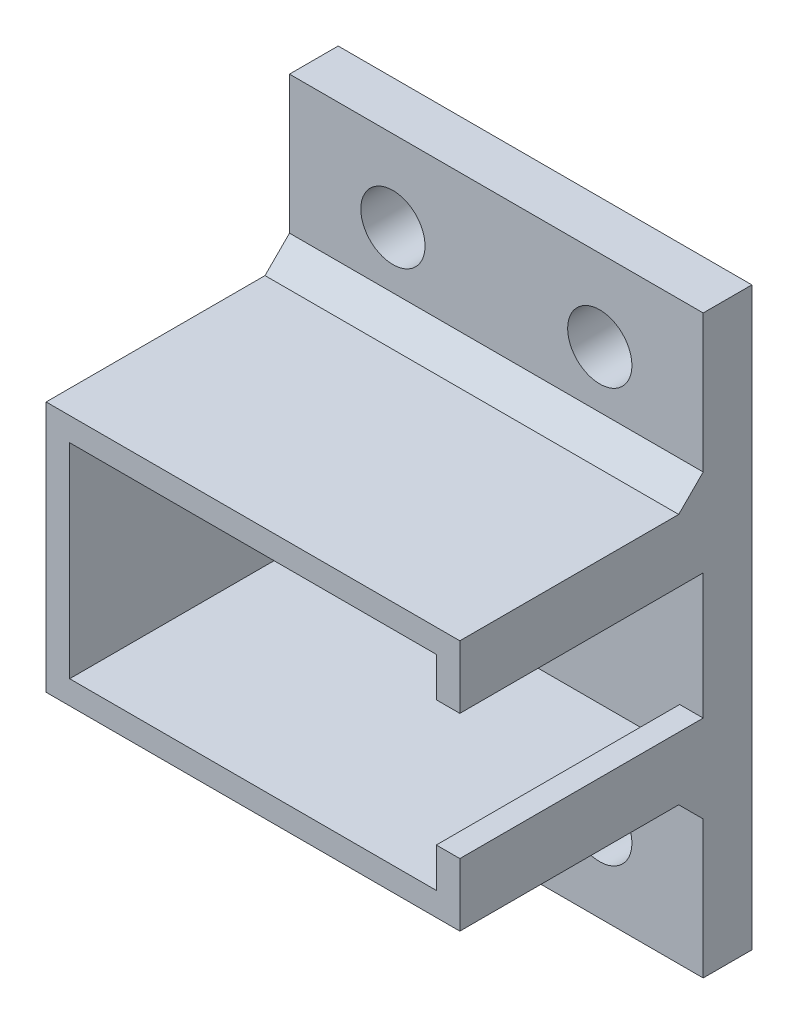
from build123d import *

# Parameters (mm, degrees)
SKETCH3_W                = 25.5
SKETCH3_H                = 15.5
BOSS_EXTRUDE2_DEPTH      = 18
SKETCH4_W                = 22.6
SKETCH4_H                = 12.6
CUT_EXTRUDE1_DEPTH       = 15
SKETCH7_W                = 25.5
SKETCH7_H                = 3
BOSS_EXTRUDE4_DEPTH      = 10
BOSS_EXTRUDE4_DEPTH_BACK = 25.5
SKETCH8_R                = 1.98
CUT_EXTRUDE2_DEPTH       = 16
CUT_EXTRUDE2_DEPTH_BACK  = 31
BOSS_EXTRUDE5_DEPTH      = 25.5
SKETCH10_W               = 15
SKETCH10_H               = 7.75
CUT_EXTRUDE3_DEPTH       = 5
CUT_EXTRUDE3_DEPTH_BACK  = 9


with BuildPart() as part:
    # Sketch3 → Boss-Extrude2 (new body)
    with BuildSketch(Plane.XY):
        with Locations((12.75, 7.75)):
            Rectangle(SKETCH3_W, SKETCH3_H)
    extrude(amount=BOSS_EXTRUDE2_DEPTH)

    # Sketch4 → Cut-Extrude1 (cut)
    with BuildSketch(Plane.XY.offset(18)):
        with Locations((12.750003743, 7.749991635)):
            Rectangle(SKETCH4_W, SKETCH4_H)
    extrude(amount=-CUT_EXTRUDE1_DEPTH, mode=Mode.SUBTRACT)

    # Sketch7 → Boss-Extrude4 (add, two sides)
    with BuildSketch(Plane.XZ) as boss_extrude4_sk:
        with Locations((12.75, 1.5)):
            Rectangle(SKETCH7_W, SKETCH7_H)
    extrude(amount=BOSS_EXTRUDE4_DEPTH)
    extrude(boss_extrude4_sk.sketch, amount=-BOSS_EXTRUDE4_DEPTH_BACK)

    # Sketch8 → Cut-Extrude2 (cut, two sides)
    with BuildSketch(Plane.XY.offset(3)) as cut_extrude2_sk:
        with Locations((19.125, 20.5)):
            Circle(SKETCH8_R)
        with Locations((6.375, -5)):
            Circle(SKETCH8_R)
        with Locations((6.375, 20.5)):
            Circle(SKETCH8_R)
        with Locations((19.125, -5)):
            Circle(SKETCH8_R)
    extrude(amount=CUT_EXTRUDE2_DEPTH, mode=Mode.SUBTRACT)
    extrude(cut_extrude2_sk.sketch, amount=-CUT_EXTRUDE2_DEPTH_BACK, mode=Mode.SUBTRACT)

    # Sketch9 → Boss-Extrude5 (add)
    with BuildSketch(Plane.ZY):
        Polygon((3, 17.01), (3, 15.5), (4.51, 15.5), align=None)
        Polygon((4.51, 0), (3, 0), (3, -1.51), align=None)
    extrude(amount=-BOSS_EXTRUDE5_DEPTH)

    # Sketch10 → Cut-Extrude3 (cut, two sides)
    with BuildSketch(Plane(origin=(25.5, 0, 0), x_dir=(0, 0, -1), z_dir=(1, 0, 0))) as cut_extrude3_sk:
        with Locations((-10.5, 7.75)):
            Rectangle(SKETCH10_W, SKETCH10_H)
    extrude(amount=CUT_EXTRUDE3_DEPTH, mode=Mode.SUBTRACT)
    extrude(cut_extrude3_sk.sketch, amount=-CUT_EXTRUDE3_DEPTH_BACK, mode=Mode.SUBTRACT)


solid = part.part
